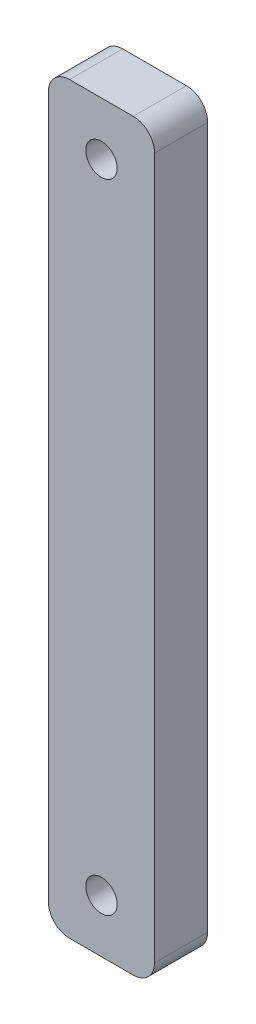
from build123d import *

# Parameters (mm, degrees)
SKETCH1_W           = 10
SKETCH1_H           = 70
SKETCH1_R           = 1.475
BOSS_EXTRUDE1_DEPTH = 5
FILLET1_R           = 2


with BuildPart() as part:
    # Sketch1 → Boss-Extrude1 (new body)
    with BuildSketch(Plane.XY):
        Rectangle(SKETCH1_W, SKETCH1_H)
        with Locations((0, 30)):
            Circle(SKETCH1_R, mode=Mode.SUBTRACT)
        with Locations((0, -30)):
            Circle(SKETCH1_R, mode=Mode.SUBTRACT)
    extrude(amount=BOSS_EXTRUDE1_DEPTH)

    # Fillet1
    fillet1_edges = [part.edges().sort_by_distance(p)[0] for p in [
        (5, -35, 2.5),
        (-5, -35, 2.5),
        (-5, 35, 2.5),
        (5, 35, 2.5),
    ]]
    fillet(fillet1_edges, radius=FILLET1_R)


solid = part.part
